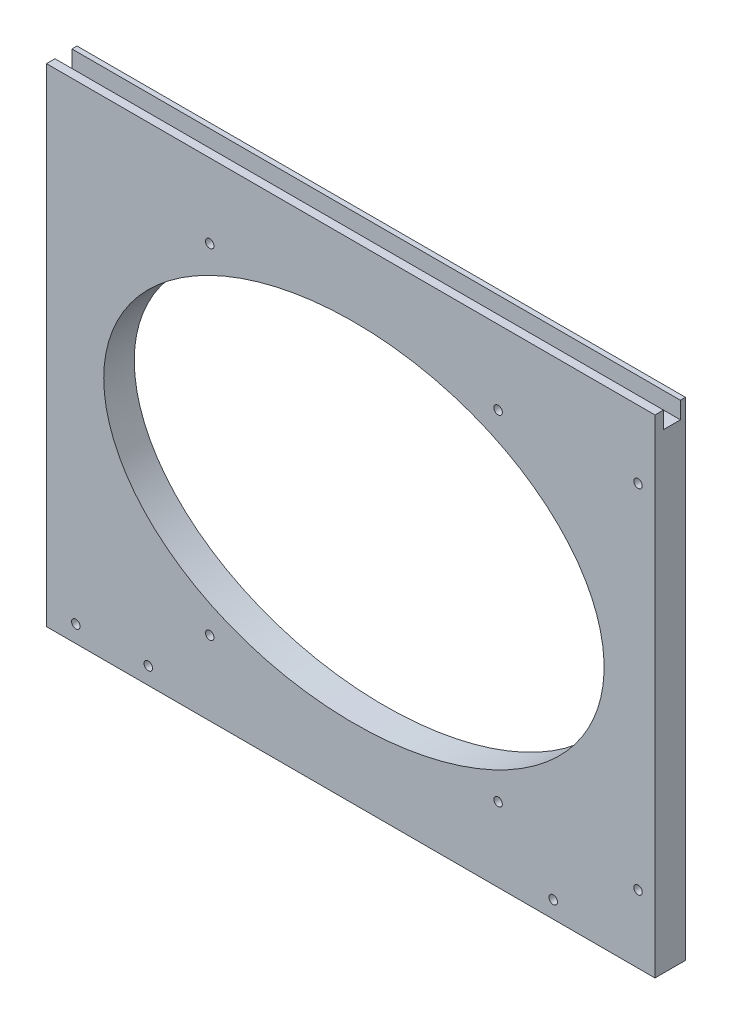
from build123d import *

# Parameters (mm, degrees)
SPEAKERMOUNTING_W               = 227.80625
SPEAKERMOUNTING_H               = 182.5625
SPEAKERMOUNTING_THICKNESS_DEPTH = 11.43
SPEAKERCUTOUT_R                 = 1.5875
SPEAKERCUTOUT_RX                = 93.6625
SPEAKERCUTOUT_RY                = 65.087499997
CUT_EXTRUDE1_DEPTH              = 11.43
CUT_EXTRUDE2_DEPTH              = 227.80625
SKETCH2_R                       = 1.5875
CUT_EXTRUDE3_DEPTH              = 11.43


with BuildPart() as part:
    # SpeakerMounting → SpeakerMounting_Thickness (new body)
    with BuildSketch(Plane.XY):
        with Locations((-5626.496875, 1089.81875)):
            Rectangle(SPEAKERMOUNTING_W, SPEAKERMOUNTING_H)
    extrude(amount=-SPEAKERMOUNTING_THICKNESS_DEPTH)

    # SpeakerCutout → Cut-Extrude1 (cut)
    with BuildSketch(Plane.XY):
        with Locations((-5571.33125, 1153.31875)):
            Circle(SPEAKERCUTOUT_R)
        with Locations((-5518.94375, 1155.7)):
            Circle(SPEAKERCUTOUT_R)
        with Locations((-5518.94375, 1023.9375)):
            Circle(SPEAKERCUTOUT_R)
        with Locations((-5550.69375, 1004.8875)):
            Circle(SPEAKERCUTOUT_R)
        with Locations((-5571.33125, 1026.31875)):
            Circle(SPEAKERCUTOUT_R)
        with Locations((-5679.28125, 1026.31875)):
            Circle(SPEAKERCUTOUT_R)
        with Locations((-5702.3, 1004.8875)):
            Circle(SPEAKERCUTOUT_R)
        with Locations((-5679.28125, 1153.31875)):
            Circle(SPEAKERCUTOUT_R)
        with Locations(Location((-5625.30625, 1089.81875), (0, 0, 180))):
            Ellipse(SPEAKERCUTOUT_RX, SPEAKERCUTOUT_RY)
    extrude(amount=-CUT_EXTRUDE1_DEPTH, mode=Mode.SUBTRACT)

    # SpeakerSlotForScreen → Cut-Extrude2 (cut)
    with BuildSketch(Plane(origin=(-5512.59375, 0, 0), x_dir=(0, 0, -1), z_dir=(1, 0, 0))):
        Polygon((5.715, 1181.1), (3.175, 1181.1), (3.175, 1174.75), (9.525, 1174.75), (9.525, 1181.1), align=None)
    extrude(amount=-CUT_EXTRUDE2_DEPTH, mode=Mode.SUBTRACT)

    # Sketch2 → Cut-Extrude3 (cut)
    with BuildSketch(Plane(origin=(0, 0, -11.43), x_dir=(-1, 0, 0), z_dir=(0, 0, -1))):
        with Locations((5729.43355, 1004.8875)):
            Circle(SKETCH2_R)
    extrude(amount=-CUT_EXTRUDE3_DEPTH, mode=Mode.SUBTRACT)


solid = part.part
